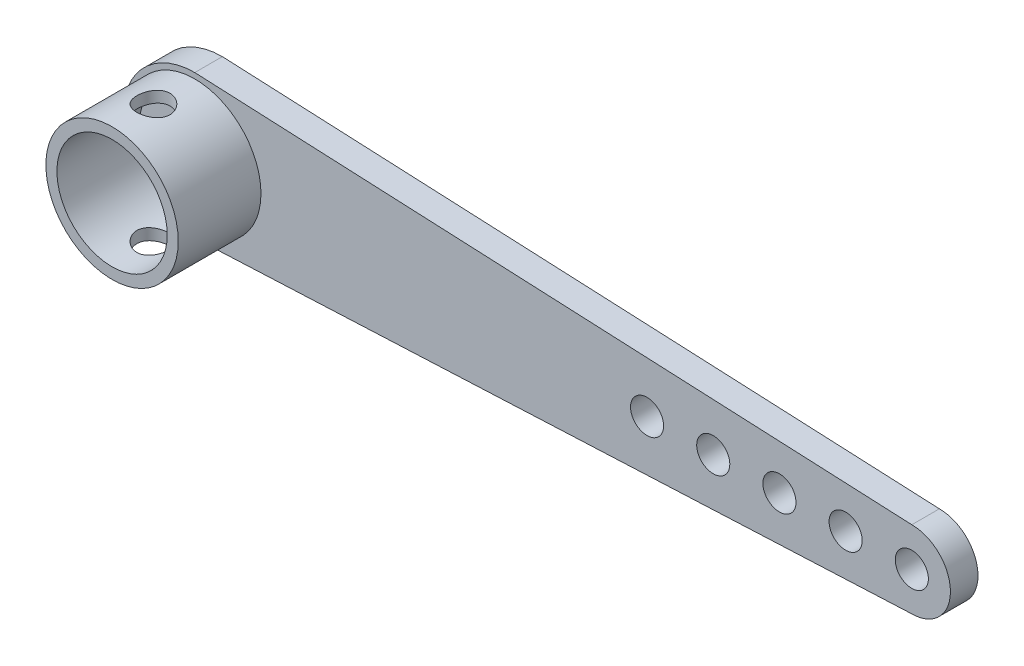
from build123d import *

# Parameters (mm, degrees)
SZKIC2_R                    = 7
DODANIE_WYCI_GNI_CIE1_DEPTH = 5
SZKIC5_R                    = 12
DODANIE_WYCI_GNI_CIE3_DEPTH = 15
SZKIC6_R                    = 10
WYTNIJ_WYCI_GNI_CIE1_DEPTH  = 15
SZKIC7_R                    = 3
WYTNIJ_WYCI_GNI_CIE2_DEPTH  = 21.5
SZKIC8_R                    = 3
WYTNIJ_WYCI_GNI_CIE3_DEPTH  = 43


with BuildPart() as part:
    # Szkic2 → Dodanie-wyciągnięcie1 (new body)
    with BuildSketch(Plane.XY):
        with BuildLine():
            Line((130, 7), (1.197449221, 12.944733113))
            ThreePointArc((1.197449221, 12.944733113), (9.606425971, 8.75880015), (13, 0))
            ThreePointArc((13, 0), (9.606425971, -8.75880015), (1.197449221, -12.944733113))
            Line((1.197449221, -12.944733113), (130, -7))
            ThreePointArc((130, -7), (123, 0), (130, 7))
        make_face()
        with Locations((130, 0)):
            Circle(SZKIC2_R)
        with BuildLine():
            Line((1.197449221, 12.944733113), (0, 13))
            ThreePointArc((0, 13), (-13, 0), (0, -13))
            Line((0, -13), (1.197449221, -12.944733113))
            ThreePointArc((1.197449221, -12.944733113), (9.606425971, -8.75880015), (13, 0))
            ThreePointArc((13, 0), (9.606425971, 8.75880015), (1.197449221, 12.944733113))
        make_face()
    extrude(amount=DODANIE_WYCI_GNI_CIE1_DEPTH)

    # Szkic5 → Dodanie-wyciągnięcie3 (add)
    with BuildSketch(Plane.XY.offset(5)):
        Circle(SZKIC5_R)
    extrude(amount=DODANIE_WYCI_GNI_CIE3_DEPTH)

    # Szkic6 → Wytnij-wyciągnięcie1 (cut)
    with BuildSketch(Plane.XY.offset(20)):
        Circle(SZKIC6_R)
    extrude(amount=-WYTNIJ_WYCI_GNI_CIE1_DEPTH, mode=Mode.SUBTRACT)

    # Szkic7 → Wytnij-wyciągnięcie2 (cut, symmetric)
    with BuildSketch(Plane(origin=(0, 0, 0), x_dir=(1, 0, 0), z_dir=(0, 1, 0))):
        with Locations((0, -12.5)):
            Circle(SZKIC7_R)
    extrude(amount=WYTNIJ_WYCI_GNI_CIE2_DEPTH, both=True, mode=Mode.SUBTRACT)

    # Szkic8 → Wytnij-wyciągnięcie3 (cut)
    with BuildSketch(Plane.XY.offset(5)):
        with Locations((130, 0)):
            Circle(SZKIC8_R)
        with Locations((118, 0)):
            Circle(SZKIC8_R)
        with Locations((106, 0)):
            Circle(SZKIC8_R)
        with Locations((94, 0)):
            Circle(SZKIC8_R)
        with Locations((82, 0)):
            Circle(SZKIC8_R)
    extrude(amount=-WYTNIJ_WYCI_GNI_CIE3_DEPTH, mode=Mode.SUBTRACT)


solid = part.part
